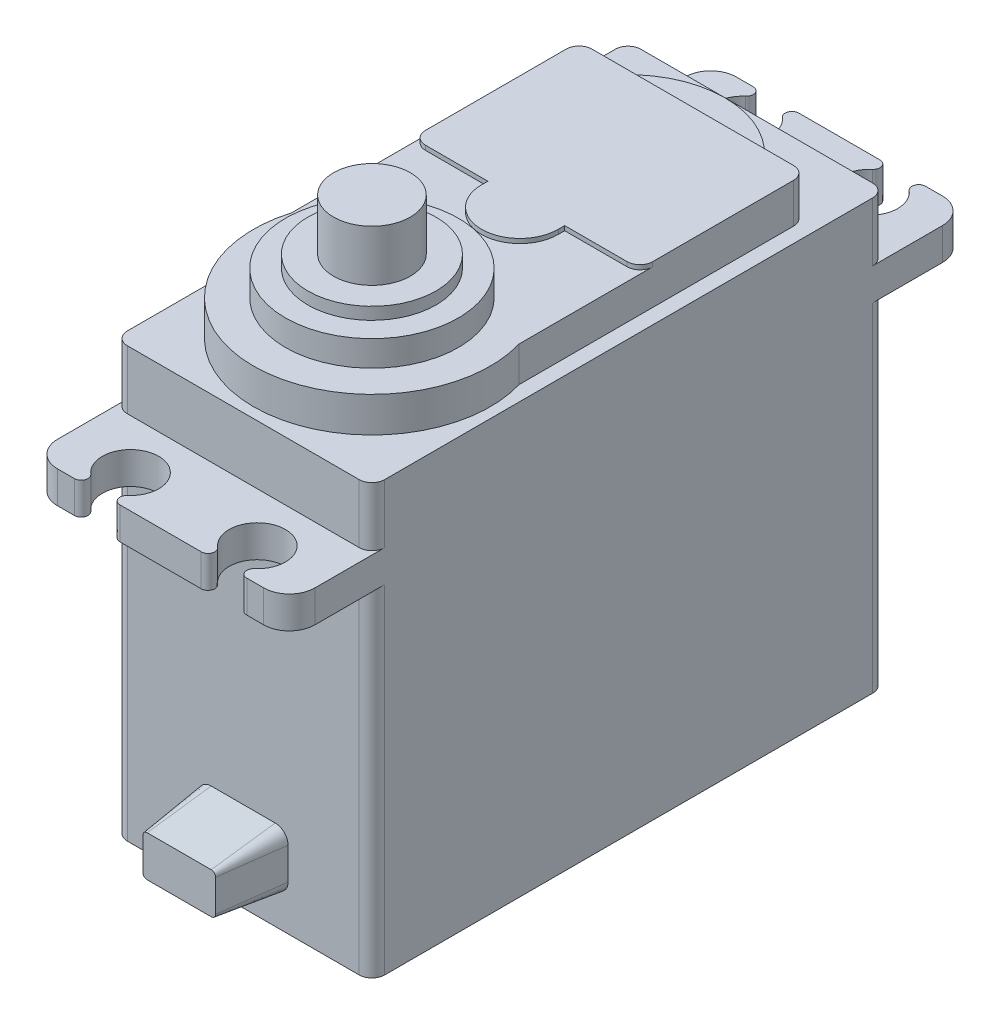
from build123d import *

# Parameters (mm, degrees)
BOSS_EXTRUDE1_DEPTH = 10.05
BOSS_EXTRUDE2_DEPTH = 2.75
SKETCH3_R           = 7.5
BOSS_EXTRUDE3_DEPTH = 2.5
SKETCH4_R           = 6.75
BOSS_EXTRUDE4_DEPTH = 2
SKETCH5_R           = 5
BOSS_EXTRUDE5_DEPTH = 0.95
SKETCH6_R           = 3
SERVO_SPLINE_DEPTH  = 4
FILLET1_R           = 1
BOSS_EXTRUDE7_DEPTH = 0.35
CUT_EXTRUDE1_DEPTH  = 29.9
FILLET2_R           = 2
FILLET3_R           = 1
BOSS_EXTRUDE8_DEPTH = 5
BOSS_EXTRUDE8_TAPER = 7.5


with BuildPart() as part:
    # Sketch1 → Boss-Extrude1 (new body, symmetric)
    with BuildSketch(Plane(origin=(0, 0, 0), x_dir=(0, 0, -1), z_dir=(1, 0, 0))):
        Polygon((-20.05, 16.75), (20.05, 16.75), (20.05, 12.15), (26.5, 12.15), (26.5, 9.65), (20.05, 9.65), (20.05, -16.75), (-20.05, -16.75), (-20.05, 9.65), (-26.5, 9.65), (-26.5, 12.15), (-20.05, 12.15), align=None)
    extrude(amount=BOSS_EXTRUDE1_DEPTH, both=True)

    # Sketch2 → Boss-Extrude2 (add)
    with BuildSketch(Plane(origin=(0, 16.75, 0), x_dir=(1, 0, 0), z_dir=(0, 1, 0))):
        with BuildLine():
            Line((-8.875, 15.05), (8.875, 15.05))
            Line((8.875, 15.05), (8.875, -7.392918298))
            ThreePointArc((8.875, -7.392918298), (0, -19.25), (-8.875, -7.392918298))
            Line((-8.875, -7.392918298), (-8.875, 15.05))
        make_face()
    extrude(amount=BOSS_EXTRUDE2_DEPTH)

    # Sketch3 → Boss-Extrude3 (add)
    with BuildSketch(Plane(origin=(0, 16.75, 0), x_dir=(1, 0, 0), z_dir=(0, 1, 0))):
        with Locations((0, 10.05)):
            Circle(SKETCH3_R)
    extrude(amount=BOSS_EXTRUDE3_DEPTH)

    # Sketch4 → Boss-Extrude4 (add)
    with BuildSketch(Plane(origin=(0, 19.5, 0), x_dir=(1, 0, 0), z_dir=(0, 1, 0))):
        with Locations((0, -10)):
            Circle(SKETCH4_R)
    extrude(amount=BOSS_EXTRUDE4_DEPTH)

    # Sketch5 → Boss-Extrude5 (add)
    with BuildSketch(Plane(origin=(0, 21.5, 0), x_dir=(1, 0, 0), z_dir=(0, 1, 0))):
        with Locations((0, -10)):
            Circle(SKETCH5_R)
    extrude(amount=BOSS_EXTRUDE5_DEPTH)

    # Sketch6 → Servo Spline (add)
    with BuildSketch(Plane(origin=(0, 22.45, 0), x_dir=(1, 0, 0), z_dir=(0, 1, 0))):
        with Locations((0, -10)):
            Circle(SKETCH6_R)
    extrude(amount=SERVO_SPLINE_DEPTH)

    # Fillet1
    fillet1_edges = [part.edges().sort_by_distance(p)[0] for p in [
        (-8.875, 18.125, -15.05),
        (8.875, 18.125, -15.05),
    ]]
    fillet(fillet1_edges, radius=FILLET1_R)

    # Sketch7 → Boss-Extrude7 (add)
    with BuildSketch(Plane(origin=(0, 19.5, 0), x_dir=(1, 0, 0), z_dir=(0, 1, 0))):
        with BuildLine():
            Line((-7.875, 2.05), (-3, 2.05))
            Line((-3, 2.05), (-3, 1.55))
            ThreePointArc((-3, 1.55), (0, -1.45), (3, 1.55))
            Line((3, 1.55), (3, 2.05))
            Line((3, 2.05), (7.875, 2.05))
            ThreePointArc((7.875, 2.05), (8.582106781, 2.342893219), (8.875, 3.05))
            Line((8.875, 3.05), (8.875, 14.05))
            ThreePointArc((8.875, 14.05), (8.582106781, 14.757106781), (7.875, 15.05))
            Line((7.875, 15.05), (-7.875, 15.05))
            ThreePointArc((-7.875, 15.05), (-8.582106781, 14.757106781), (-8.875, 14.05))
            Line((-8.875, 14.05), (-8.875, 3.05))
            ThreePointArc((-8.875, 3.05), (-8.582106781, 2.342893219), (-7.875, 2.05))
        make_face()
    extrude(amount=BOSS_EXTRUDE7_DEPTH)

    # Sketch8 → Cut-Extrude1 (cut, through all)
    with BuildSketch(Plane(origin=(0, 12.15, 0), x_dir=(1, 0, 0), z_dir=(0, 1, 0))):
        with BuildLine():
            Line((6.730066226, -26.5), (3.169933774, -26.5))
            ThreePointArc((3.169933774, -26.5), (3.666925505, -26.154241731), (3.515549194, -25.568038035))
            ThreePointArc((3.515549194, -25.568038035), (4.95, -21.7), (6.384450806, -25.568038035))
            ThreePointArc((6.384450806, -25.568038035), (6.233074495, -26.154241731), (6.730066226, -26.5))
        make_face()
        with BuildLine():
            Line((-3.169933774, -26.5), (-6.730066226, -26.5))
            ThreePointArc((-6.730066226, -26.5), (-6.233074495, -26.154241731), (-6.384450806, -25.568038035))
            ThreePointArc((-6.384450806, -25.568038035), (-4.95, -21.7), (-3.515549194, -25.568038035))
            ThreePointArc((-3.515549194, -25.568038035), (-3.666925505, -26.154241731), (-3.169933774, -26.5))
        make_face()
        with BuildLine():
            Line((-6.730066226, 26.5), (-3.169933774, 26.5))
            ThreePointArc((-3.169933774, 26.5), (-3.666925505, 26.154241731), (-3.515549194, 25.568038035))
            ThreePointArc((-3.515549194, 25.568038035), (-4.95, 21.7), (-6.384450806, 25.568038035))
            ThreePointArc((-6.384450806, 25.568038035), (-6.233074495, 26.154241731), (-6.730066226, 26.5))
        make_face()
        with BuildLine():
            Line((3.169933774, 26.5), (6.730066226, 26.5))
            ThreePointArc((6.730066226, 26.5), (6.233074495, 26.154241731), (6.384450806, 25.568038035))
            ThreePointArc((6.384450806, 25.568038035), (4.95, 21.7), (3.515549194, 25.568038035))
            ThreePointArc((3.515549194, 25.568038035), (3.666925505, 26.154241731), (3.169933774, 26.5))
        make_face()
    extrude(amount=-CUT_EXTRUDE1_DEPTH, mode=Mode.SUBTRACT)

    # Fillet2
    fillet2_edges = [part.edges().sort_by_distance(p)[0] for p in [
        (10.05, 10.9, 26.5),
        (-10.05, 10.9, -26.5),
        (-10.05, 10.9, 26.5),
        (10.05, 10.9, -26.5),
    ]]
    fillet(fillet2_edges, radius=FILLET2_R)

    # Fillet3
    fillet3_edges = [part.edges().sort_by_distance(p)[0] for p in [
        (-10.05, 14.45, -20.05),
        (-10.05, -3.55, -20.05),
        (-10.05, -3.55, 20.05),
        (-10.05, 14.45, 20.05),
        (10.05, -3.55, 20.05),
        (10.05, -3.55, -20.05),
        (10.05, 14.45, -20.05),
        (10.05, 14.45, 20.05),
    ]]
    fillet(fillet3_edges, radius=FILLET3_R)

    # Sketch9 → Boss-Extrude8 (add)
    with BuildSketch(Plane.XY.offset(20.05)):
        with BuildLine():
            Line((-2.5, -14.25), (2.5, -14.25))
            ThreePointArc((2.5, -14.25), (3.207106781, -13.957106781), (3.5, -13.25))
            Line((3.5, -13.25), (3.5, -10.75))
            ThreePointArc((3.5, -10.75), (3.207106781, -10.042893219), (2.5, -9.75))
            Line((2.5, -9.75), (-2.5, -9.75))
            ThreePointArc((-2.5, -9.75), (-3.207106781, -10.042893219), (-3.5, -10.75))
            Line((-3.5, -10.75), (-3.5, -13.25))
            ThreePointArc((-3.5, -13.25), (-3.207106781, -13.957106781), (-2.5, -14.25))
        make_face()
    extrude(amount=BOSS_EXTRUDE8_DEPTH, taper=BOSS_EXTRUDE8_TAPER)


solid = part.part
